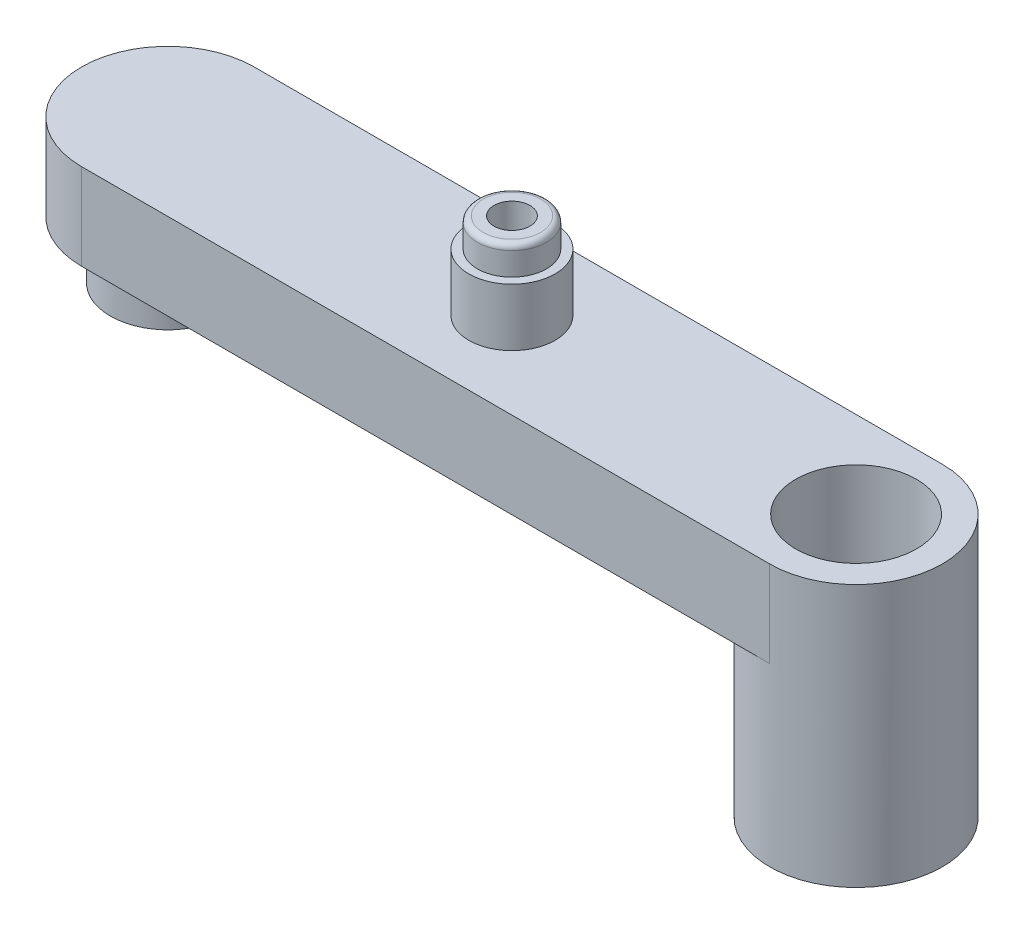
from build123d import *

# Parameters (mm, degrees)
BOSS_EXTRUDE1_DEPTH = 3
SKETCH2_R           = 2
BOSS_EXTRUDE2_DEPTH = 2
SKETCH3_R           = 1.1
CUT_EXTRUDE1_DEPTH  = 3.5
SKETCH4_R           = 3
BOSS_EXTRUDE3_DEPTH = 6.12
SKETCH5_R           = 2.1
CUT_EXTRUDE3_DEPTH  = 9.12
SKETCH7_R           = 1.5
BOSS_EXTRUDE4_DEPTH = 2
SKETCH8_R           = 1.2
BOSS_EXTRUDE5_DEPTH = 1
SKETCH9_R           = 0.625
CUT_EXTRUDE6_DEPTH  = 3.5
FILLET2_R           = 0.2


with BuildPart() as part:
    # Sketch1 → Boss-Extrude1 (new body)
    with BuildSketch(Plane(origin=(0, 0, 0), x_dir=(1, 0, 0), z_dir=(0, 1, 0))):
        with BuildLine():
            Line((-11.96, 3), (11.96, 3))
            ThreePointArc((11.96, 3), (14.96, 0), (11.96, -3))
            Line((11.96, -3), (-11.96, -3))
            ThreePointArc((-11.96, -3), (-14.96, 0), (-11.96, 3))
        make_face()
    extrude(amount=BOSS_EXTRUDE1_DEPTH)

    # Sketch2 → Boss-Extrude2 (add)
    with BuildSketch(Plane.XZ):
        with Locations(Location((-11.96, 0, 0), (0, 0, 90))):
            Circle(SKETCH2_R)
    extrude(amount=BOSS_EXTRUDE2_DEPTH)

    # Sketch3 → Cut-Extrude1 (cut)
    with BuildSketch(Plane.XZ.offset(2)):
        with Locations(Location((-11.96, 0, 0), (0, 0, 270))):
            Circle(SKETCH3_R)
    extrude(amount=-CUT_EXTRUDE1_DEPTH, mode=Mode.SUBTRACT)

    # Sketch4 → Boss-Extrude3 (add)
    with BuildSketch(Plane.XZ):
        with Locations(Location((11.96, 0, 0), (0, 0, 270))):
            Circle(SKETCH4_R)
    extrude(amount=BOSS_EXTRUDE3_DEPTH)

    # Sketch5 → Cut-Extrude3 (cut)
    with BuildSketch(Plane.XZ.offset(6.12)):
        with Locations(Location((11.96, 0, 0), (0, 0, 270))):
            Circle(SKETCH5_R)
    extrude(amount=-CUT_EXTRUDE3_DEPTH, mode=Mode.SUBTRACT)

    # Sketch7 → Boss-Extrude4 (add)
    with BuildSketch(Plane(origin=(0, 3, 0), x_dir=(1, 0, 0), z_dir=(0, 1, 0))):
        with Locations(Location((0, 0, 0), (0, 0, 270))):
            Circle(SKETCH7_R)
    extrude(amount=BOSS_EXTRUDE4_DEPTH)

    # Sketch8 → Boss-Extrude5 (add)
    with BuildSketch(Plane(origin=(0, 5, 0), x_dir=(1, 0, 0), z_dir=(0, 1, 0))):
        with Locations(Location((0, 0, 0), (0, 0, 270))):
            Circle(SKETCH8_R)
    extrude(amount=BOSS_EXTRUDE5_DEPTH)

    # Sketch9 → Cut-Extrude6 (cut)
    with BuildSketch(Plane(origin=(0, 6, 0), x_dir=(1, 0, 0), z_dir=(0, 1, 0))):
        with Locations(Location((0, 0, 0), (0, 0, 270))):
            Circle(SKETCH9_R)
    extrude(amount=-CUT_EXTRUDE6_DEPTH, mode=Mode.SUBTRACT)

    # Fillet2
    fillet2_edges = [part.edges().sort_by_distance(p)[0] for p in [
        (0, 6, -1.2),
    ]]
    fillet(fillet2_edges, radius=FILLET2_R)


solid = part.part
